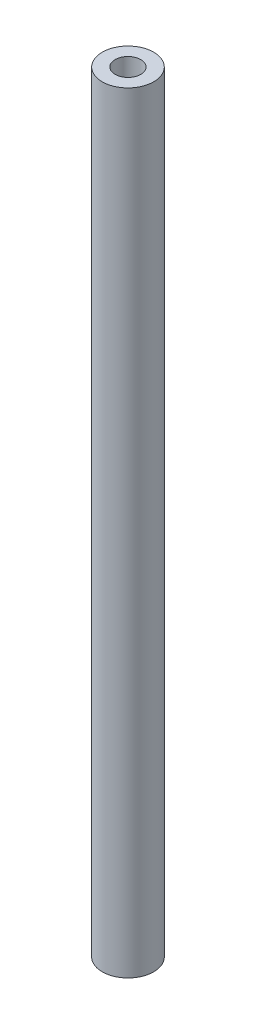
from build123d import *

# Parameters (mm, degrees)
SKETCH1_R           = 12.7
SKETCH1_R_2         = 6.35
BOSS_EXTRUDE1_DEPTH = 381


with BuildPart() as part:
    # Sketch1 → Boss-Extrude1 (new body)
    with BuildSketch(Plane(origin=(0, 0, 0), x_dir=(1, 0, 0), z_dir=(0, 1, 0))):
        Circle(SKETCH1_R)
        Circle(SKETCH1_R_2, mode=Mode.SUBTRACT)
    extrude(amount=BOSS_EXTRUDE1_DEPTH)


solid = part.part
